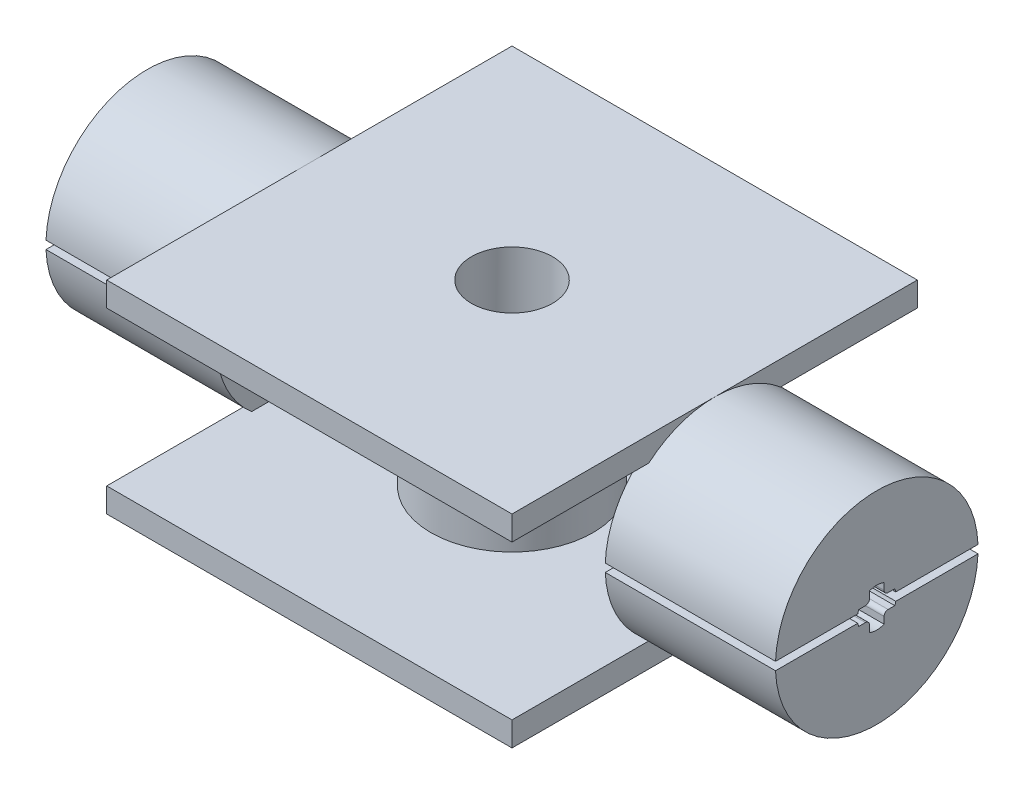
from build123d import *

# Parameters (mm, degrees)
SKETCH1_R                = 10
BOSS_EXTRUDE1_DEPTH      = 19
SKETCH3_W                = 50
SKETCH3_H                = 50
BOSS_EXTRUDE2_DEPTH      = 3
SKETCH5_W                = 50
SKETCH5_H                = 50
BOSS_EXTRUDE4_DEPTH      = 3
SKETCH7_R                = 12.5
BOSS_EXTRUDE5_DEPTH      = 20
BOSS_EXTRUDE5_DEPTH_BACK = 1
SKETCH8_R                = 10
BOSS_EXTRUDE6_DEPTH      = 20
BOSS_EXTRUDE6_DEPTH_BACK = 1
SKETCH9_W                = 28.965508976
SKETCH9_H                = 1
CUT_EXTRUDE2_DEPTH       = 21
SKETCH10_W               = 34.685430092
SKETCH10_H               = 1
CUT_EXTRUDE3_DEPTH       = 21
SKETCH6_R                = 5
CUT_EXTRUDE4_DEPTH       = 58.227615711
CUT_EXTRUDE5_START       = -4
SKETCH11_R               = 10.5
CUT_EXTRUDE5_DEPTH       = 13
CUT_EXTRUDE6_DEPTH       = 96.963534741


with BuildPart() as part:
    # Sketch1 → Boss-Extrude1 (new body)
    with BuildSketch(Plane(origin=(0, 0, 0), x_dir=(1, 0, 0), z_dir=(0, 1, 0))):
        with Locations(Location((0, 0, 0), (0, 0, 270))):
            Circle(SKETCH1_R)
    extrude(amount=BOSS_EXTRUDE1_DEPTH)

    # Sketch3 → Boss-Extrude2 (add)
    with BuildSketch(Plane.XZ):
        Rectangle(SKETCH3_W, SKETCH3_H)
    extrude(amount=BOSS_EXTRUDE2_DEPTH)

    # Sketch5 → Boss-Extrude4 (add)
    with BuildSketch(Plane(origin=(0, 19, 0), x_dir=(1, 0, 0), z_dir=(0, 1, 0))):
        Rectangle(SKETCH5_W, SKETCH5_H)
    extrude(amount=BOSS_EXTRUDE4_DEPTH)

    # Sketch7 → Boss-Extrude5 (add, two sides)
    with BuildSketch(Plane.ZY.offset(25)) as boss_extrude5_sk:
        with Locations((0, 9.5)):
            Circle(SKETCH7_R)
    extrude(amount=BOSS_EXTRUDE5_DEPTH)
    extrude(boss_extrude5_sk.sketch, amount=-BOSS_EXTRUDE5_DEPTH_BACK)

    # Sketch8 → Boss-Extrude6 (add, two sides)
    with BuildSketch(Plane(origin=(25, 0, 0), x_dir=(0, 0, -1), z_dir=(1, 0, 0))) as boss_extrude6_sk:
        with Locations((0, 9.5)):
            Circle(SKETCH8_R)
    extrude(amount=BOSS_EXTRUDE6_DEPTH)
    extrude(boss_extrude6_sk.sketch, amount=-BOSS_EXTRUDE6_DEPTH_BACK)

    # Sketch9 → Cut-Extrude2 (cut)
    with BuildSketch(Plane.ZY.offset(45)):
        with Locations((0, 9.5)):
            Rectangle(SKETCH9_W, SKETCH9_H)
    extrude(amount=-CUT_EXTRUDE2_DEPTH, mode=Mode.SUBTRACT)

    # Sketch10 → Cut-Extrude3 (cut)
    with BuildSketch(Plane(origin=(45, 0, 0), x_dir=(0, 0, -1), z_dir=(1, 0, 0))):
        with Locations((0, 9.5)):
            Rectangle(SKETCH10_W, SKETCH10_H)
    extrude(amount=-CUT_EXTRUDE3_DEPTH, mode=Mode.SUBTRACT)

    # Sketch6 → Cut-Extrude4 (cut, through all)
    with BuildSketch(Plane(origin=(0, 22, 0), x_dir=(1, 0, 0), z_dir=(0, 1, 0))):
        with Locations(Location((0, 0, 0), (0, 0, 270))):
            Circle(SKETCH6_R)
    extrude(amount=-CUT_EXTRUDE4_DEPTH, mode=Mode.SUBTRACT)

    # Sketch11 → Cut-Extrude5 (cut)
    with BuildSketch(Plane.ZY.offset(45).offset(CUT_EXTRUDE5_START)):
        with Locations((0, 9.5)):
            Circle(SKETCH11_R)
    extrude(amount=-CUT_EXTRUDE5_DEPTH, mode=Mode.SUBTRACT)

    # SurfaceCut1
    split(bisect_by=Plane(origin=(0, 0, 0), x_dir=(0, 0, -1), z_dir=(1, 0, 0)), keep=Keep.BOTTOM)

    # Mirror2: part across plane


with BuildPart() as part_1:
    add(part.part)
    add(part.part.mirror(Plane(origin=(0, 0, 0), x_dir=(0, 0, 1), z_dir=(1, 0, 0))))

    # Sketch12 → Cut-Extrude6 (cut, through all)
    with BuildSketch(Plane.ZY.offset(45)):
        with BuildLine():
            Line((-1.4, 10.4), (-2.224859546, 10.4))
            ThreePointArc((-2.224859546, 10.4), (-2.4, 9.5), (-2.224859546, 8.6))
            Line((-2.224859546, 8.6), (-1.4, 8.6))
            ThreePointArc((-1.4, 8.6), (-1.046446609, 8.453553391), (-0.9, 8.1))
            Line((-0.9, 8.1), (-0.9, 7.275140454))
            ThreePointArc((-0.9, 7.275140454), (0, 7.1), (0.9, 7.275140454))
            Line((0.9, 7.275140454), (0.9, 8.1))
            ThreePointArc((0.9, 8.1), (1.046446609, 8.453553391), (1.4, 8.6))
            Line((1.4, 8.6), (2.224859546, 8.6))
            ThreePointArc((2.224859546, 8.6), (2.4, 9.5), (2.224859546, 10.4))
            Line((2.224859546, 10.4), (1.4, 10.4))
            ThreePointArc((1.4, 10.4), (1.046446609, 10.546446609), (0.9, 10.9))
            Line((0.9, 10.9), (0.9, 11.724859546))
            ThreePointArc((0.9, 11.724859546), (0, 11.9), (-0.9, 11.724859546))
            Line((-0.9, 11.724859546), (-0.9, 10.9))
            ThreePointArc((-0.9, 10.9), (-1.046446609, 10.546446609), (-1.4, 10.4))
        make_face()
    extrude(amount=-CUT_EXTRUDE6_DEPTH, mode=Mode.SUBTRACT)


solid = part_1.part
